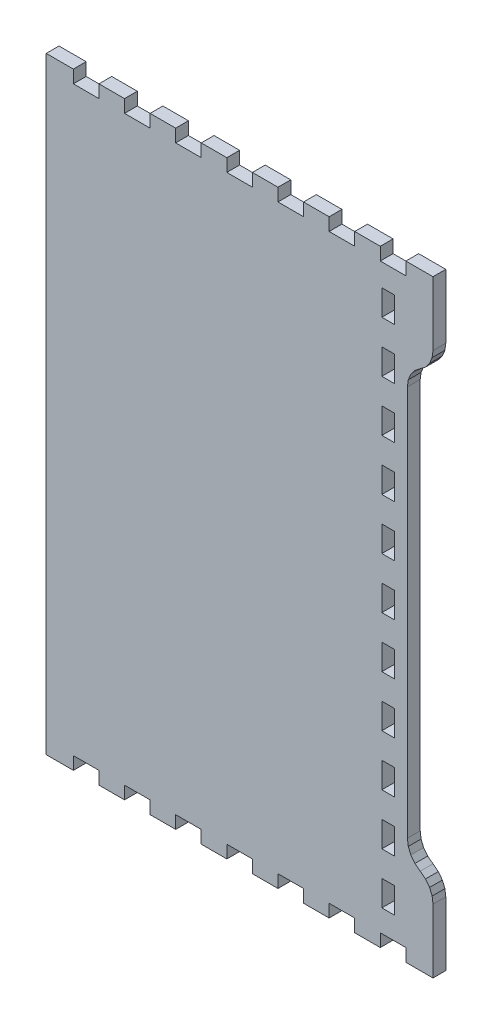
from build123d import *

# Parameters (mm, degrees)
BOSS_EXTRUDE1_DEPTH = 5.715


with BuildPart() as part:
    # Model → Boss-Extrude1 (new body)
    with BuildSketch(Plane.XY):
        Polygon((1288.610132665, 22.860238699), (1300.745973293, 22.860238699), (1300.745973293, 28.575245224), (1312.176695005, 28.575245224), (1312.176695005, 22.860238699), (1323.607416717, 22.860238699), (1323.607416717, 28.575245224), (1335.038138429, 28.575245224), (1335.038138429, 22.860238699), (1346.46531683, 22.860238699), (1346.46531683, 28.575245224), (1357.896038543, 28.575245224), (1357.896038543, 22.860238699), (1369.326760255, 22.860238699), (1369.326760255, 28.575245224), (1380.757481967, 28.575245224), (1380.757481967, 22.860238699), (1392.188203679, 22.860238699), (1392.188203679, 28.575245224), (1403.615382081, 28.575245224), (1403.615382081, 22.860238699), (1415.046103793, 22.860238699), (1415.046103793, 28.575245224), (1426.476825505, 28.575245224), (1426.476825505, 22.860238699), (1437.907547217, 22.860238699), (1437.907547217, 28.575245224), (1449.33826893, 28.575245224), (1449.33826893, 22.860238699), (1461.470566246, 22.860238699), (1461.470566246, 28.575245224), (1461.470566246, 51.435413056), (1461.081244935, 54.393369189), (1459.939855837, 57.150419581), (1458.123908882, 59.517571103), (1455.75520539, 61.334361366), (1453.389602295, 63.150485487), (1451.574098254, 65.517240157), (1450.429608758, 68.274290549), (1450.039844534, 71.232246682), (1450.039844534, 245.918194159), (1450.429608758, 248.876284937), (1451.574098254, 251.633200684), (1453.389602295, 254.00013252), (1455.75520539, 255.816433806), (1458.123908882, 257.633089424), (1459.939855837, 260.000375591), (1461.081244935, 262.757291337), (1461.470566246, 265.715382116), (1461.470566246, 288.575408216), (1461.470566246, 294.290414741), (1449.33826893, 294.290414741), (1449.33826893, 288.575408216), (1437.907547217, 288.575408216), (1437.907547217, 294.290414741), (1426.476825505, 294.290414741), (1426.476825505, 288.575408216), (1415.046103793, 288.575408216), (1415.046103793, 294.290414741), (1403.615382081, 294.290414741), (1403.615382081, 288.575408216), (1392.188203679, 288.575408216), (1392.188203679, 294.290414741), (1380.757481967, 294.290414741), (1380.757481967, 288.575408216), (1369.326760255, 288.575408216), (1369.326760255, 294.290414741), (1357.896038543, 294.290414741), (1357.896038543, 288.575408216), (1346.46531683, 288.575408216), (1346.46531683, 294.290414741), (1335.038138429, 294.290414741), (1335.038138429, 288.575408216), (1323.607416717, 288.575408216), (1323.607416717, 294.290414741), (1312.176695005, 294.290414741), (1312.176695005, 288.575408216), (1300.745973293, 288.575408216), (1300.745973293, 294.290414741), (1288.610132665, 294.290414741), (1288.610132665, 288.575408216), (1288.610132665, 28.575245224), align=None)
        Polygon((1444.328026989, 44.27508992), (1444.328026989, 38.560083395), (1438.612666133, 38.560083395), (1438.612666133, 49.990096445), (1444.328026989, 49.990096445), align=None, mode=Mode.SUBTRACT)
        Polygon((1444.328026989, 67.13511602), (1444.328026989, 61.420109495), (1438.612666133, 61.420109495), (1438.612666133, 72.850122545), (1444.328026989, 72.850122545), align=None, mode=Mode.SUBTRACT)
        Polygon((1444.328026989, 89.99514212), (1444.328026989, 84.280135595), (1438.612666133, 84.280135595), (1438.612666133, 95.710148645), (1444.328026989, 95.710148645), align=None, mode=Mode.SUBTRACT)
        Polygon((1444.328026989, 112.85516822), (1444.328026989, 107.140161695), (1438.612666133, 107.140161695), (1438.612666133, 118.570174745), (1444.328026989, 118.570174745), align=None, mode=Mode.SUBTRACT)
        Polygon((1444.328026989, 135.71519432), (1444.328026989, 130.000187795), (1438.612666133, 130.000187795), (1438.612666133, 141.430200846), (1444.328026989, 141.430200846), align=None, mode=Mode.SUBTRACT)
        Polygon((1444.328026989, 158.575220421), (1444.328026989, 152.860213896), (1438.612666133, 152.860213896), (1438.612666133, 164.290226946), (1444.328026989, 164.290226946), align=None, mode=Mode.SUBTRACT)
        Polygon((1444.328026989, 181.435246521), (1444.328026989, 175.720239996), (1438.612666133, 175.720239996), (1438.612666133, 187.150253046), (1444.328026989, 187.150253046), align=None, mode=Mode.SUBTRACT)
        Polygon((1444.328026989, 204.295272621), (1444.328026989, 198.580266096), (1438.612666133, 198.580266096), (1438.612666133, 210.010279146), (1444.328026989, 210.010279146), align=None, mode=Mode.SUBTRACT)
        Polygon((1444.328026989, 227.155298721), (1444.328026989, 221.440292196), (1438.612666133, 221.440292196), (1438.612666133, 232.870305246), (1444.328026989, 232.870305246), align=None, mode=Mode.SUBTRACT)
        Polygon((1444.328026989, 250.015324821), (1444.328026989, 244.300318296), (1438.612666133, 244.300318296), (1438.612666133, 255.730331346), (1444.328026989, 255.730331346), align=None, mode=Mode.SUBTRACT)
        Polygon((1444.328026989, 272.875350921), (1444.328026989, 267.160344396), (1438.612666133, 267.160344396), (1438.612666133, 278.590357446), (1444.328026989, 278.590357446), align=None, mode=Mode.SUBTRACT)
    extrude(amount=BOSS_EXTRUDE1_DEPTH)


solid = part.part
